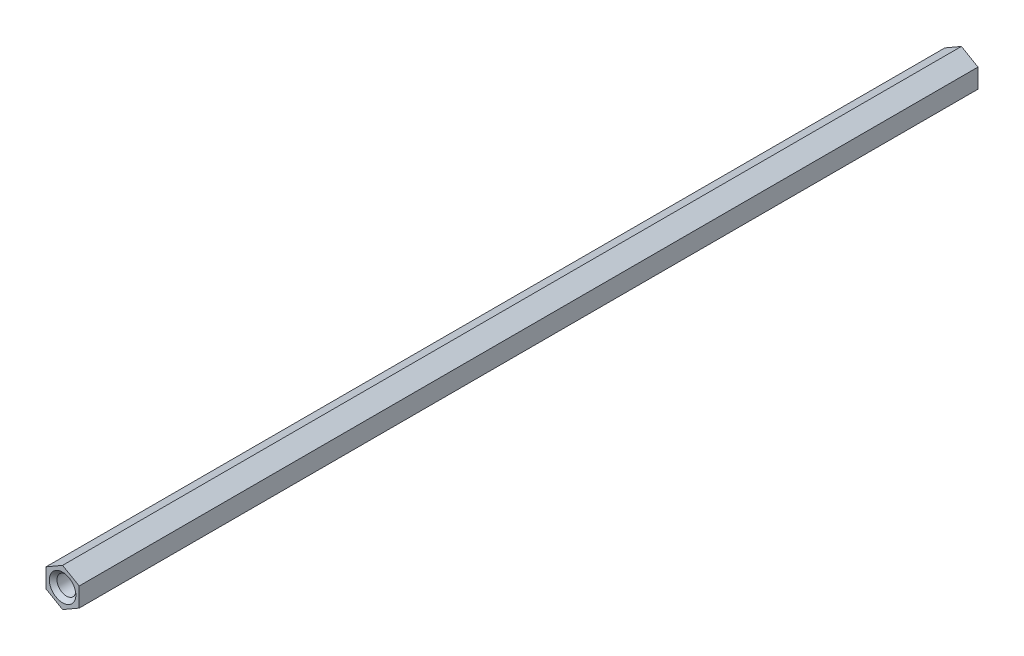
from build123d import *

# Parameters (mm, degrees)
BOSS_EXTRUDE1_DEPTH               = 129
F_1_4_28_TAPPED_HOLE1_D           = 5.4102
F_1_4_28_TAPPED_HOLE1_DEPTH       = 15.24
F_1_4_28_TAPPED_HOLE1_CSINK_D     = 7.62
F_1_4_28_TAPPED_HOLE1_CSINK_ANGLE = 90
F_1_4_28_TAPPED_HOLE1_TIP         = 1.625388061
F_1_4_28_TAPPED_HOLE2_D           = 5.4102
F_1_4_28_TAPPED_HOLE2_DEPTH       = 17.2339
F_1_4_28_TAPPED_HOLE2_CSINK_D     = 7.62
F_1_4_28_TAPPED_HOLE2_CSINK_ANGLE = 90
F_1_4_28_TAPPED_HOLE2_TIP         = 1.625388061


with BuildPart() as part:
    # Sketch3 → Boss-Extrude1 (new, symmetric)
    with BuildSketch(Plane.XY):
        Polygon((0, 5.499261314), (4.7625, 2.749630657), (4.7625, -2.749630657), (0, -5.499261314), (-4.7625, -2.749630657), (-4.7625, 2.749630657), align=None)
    extrude(amount=BOSS_EXTRUDE1_DEPTH, both=True)

    # 1/4-28 Tapped Hole1
    with Locations(Plane.XY.offset(129)):
        with Locations((0, 0)):
            CounterSinkHole(F_1_4_28_TAPPED_HOLE1_D / 2, F_1_4_28_TAPPED_HOLE1_CSINK_D / 2, depth=F_1_4_28_TAPPED_HOLE1_DEPTH, counter_sink_angle=F_1_4_28_TAPPED_HOLE1_CSINK_ANGLE)
            with Locations((0, 0, -(F_1_4_28_TAPPED_HOLE1_DEPTH + F_1_4_28_TAPPED_HOLE1_TIP / 2))):  # 118° drill point
                Cone(0, F_1_4_28_TAPPED_HOLE1_D / 2, F_1_4_28_TAPPED_HOLE1_TIP, mode=Mode.SUBTRACT)

    # 1/4-28 Tapped Hole2
    with Locations(Plane(origin=(0, 0, -129), x_dir=(-1, 0, 0), z_dir=(0, 0, -1))):
        with Locations((0, 0)):
            CounterSinkHole(F_1_4_28_TAPPED_HOLE2_D / 2, F_1_4_28_TAPPED_HOLE2_CSINK_D / 2, depth=F_1_4_28_TAPPED_HOLE2_DEPTH, counter_sink_angle=F_1_4_28_TAPPED_HOLE2_CSINK_ANGLE)
            with Locations((0, 0, -(F_1_4_28_TAPPED_HOLE2_DEPTH + F_1_4_28_TAPPED_HOLE2_TIP / 2))):  # 118° drill point
                Cone(0, F_1_4_28_TAPPED_HOLE2_D / 2, F_1_4_28_TAPPED_HOLE2_TIP, mode=Mode.SUBTRACT)


solid = part.part
